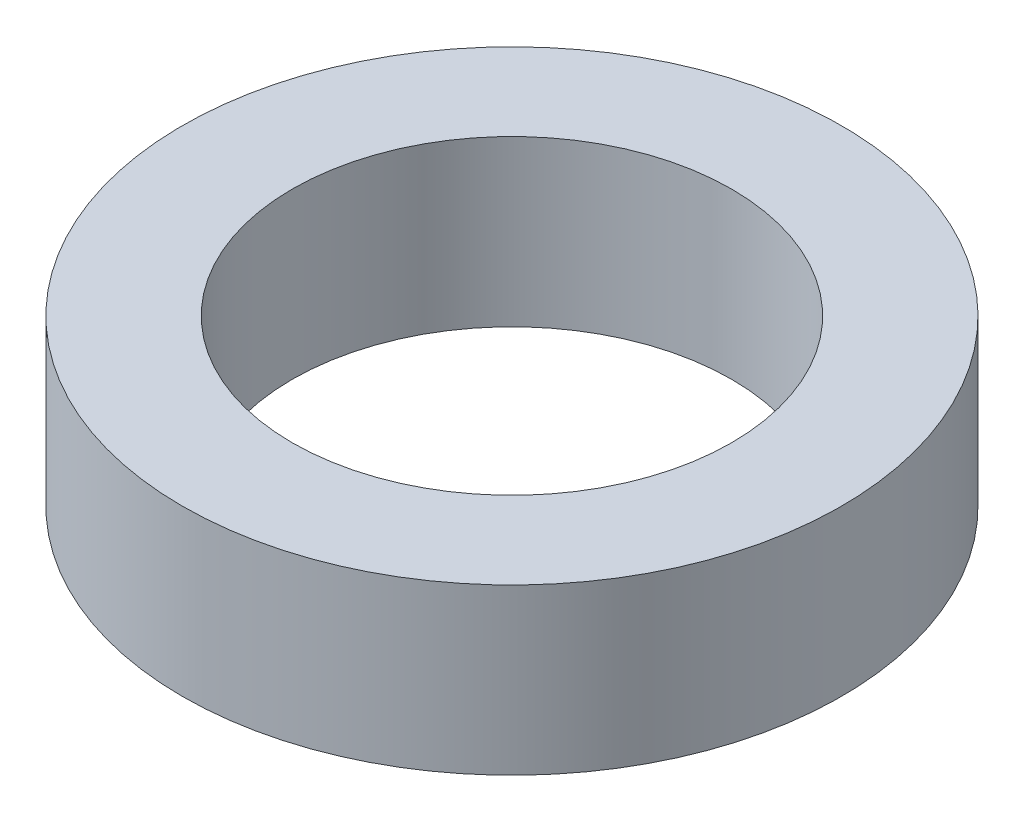
from build123d import *

# Parameters (mm, degrees)
SKETCH1_R           = 9.525
SKETCH1_R_2         = 6.35
BOSS_EXTRUDE1_DEPTH = 4.7625


with BuildPart() as part:
    # Sketch1 → Boss-Extrude1 (new body)
    with BuildSketch(Plane(origin=(0, 0, 0), x_dir=(1, 0, 0), z_dir=(0, 1, 0))):
        Circle(SKETCH1_R)
        Circle(SKETCH1_R_2, mode=Mode.SUBTRACT)
    extrude(amount=BOSS_EXTRUDE1_DEPTH)


solid = part.part
